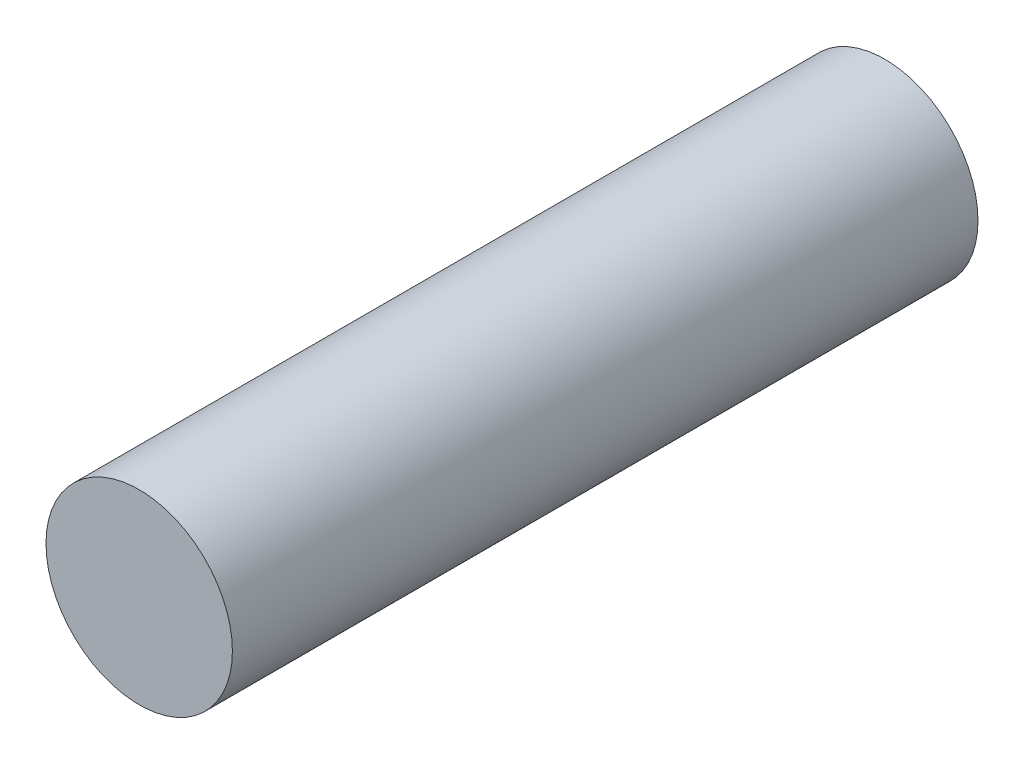
from build123d import *

# Parameters (mm, degrees)
SKETCH_1_R      = 0.75
EXTRUDE_1_DEPTH = 3


with BuildPart() as part:
    # 草圖1 → 填料-伸長1 (new body, symmetric)
    with BuildSketch(Plane.XY):
        Circle(SKETCH_1_R)
    extrude(amount=EXTRUDE_1_DEPTH, both=True)


solid = part.part
